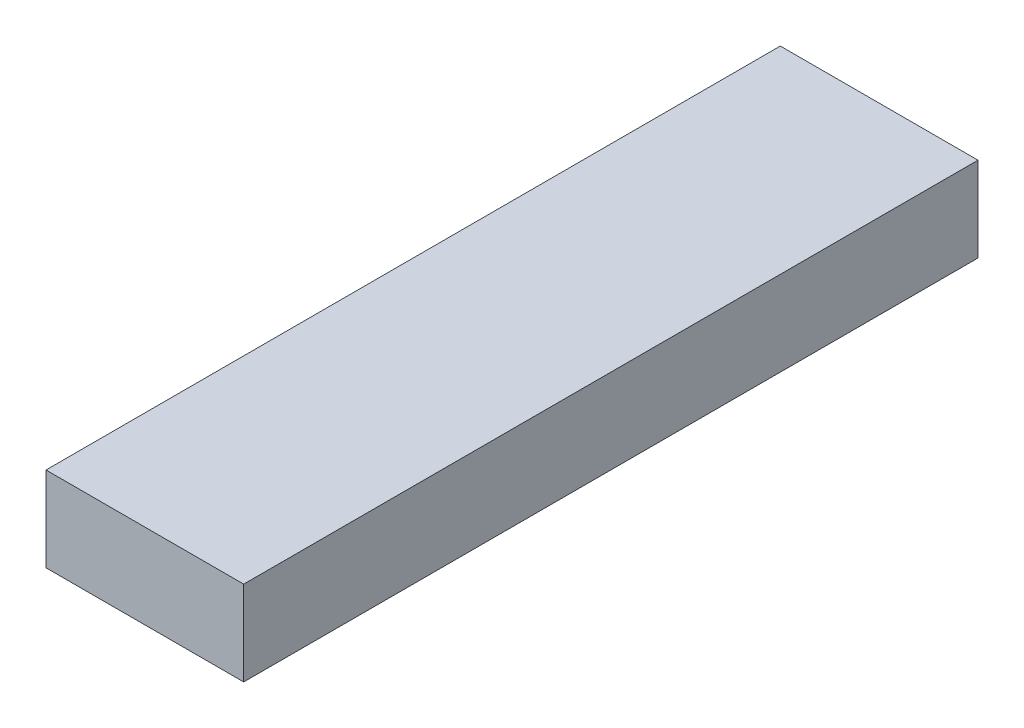
from build123d import *

# Parameters (mm, degrees)
SKETCH1_W           = 88.9
SKETCH1_H           = 38.1
BOSS_EXTRUDE1_DEPTH = 330.2


with BuildPart() as part:
    # Sketch1 → Boss-Extrude1 (new body)
    with BuildSketch(Plane.XY):
        with Locations((124.633826816, 80.175958359)):
            Rectangle(SKETCH1_W, SKETCH1_H)
    extrude(amount=BOSS_EXTRUDE1_DEPTH)


solid = part.part
